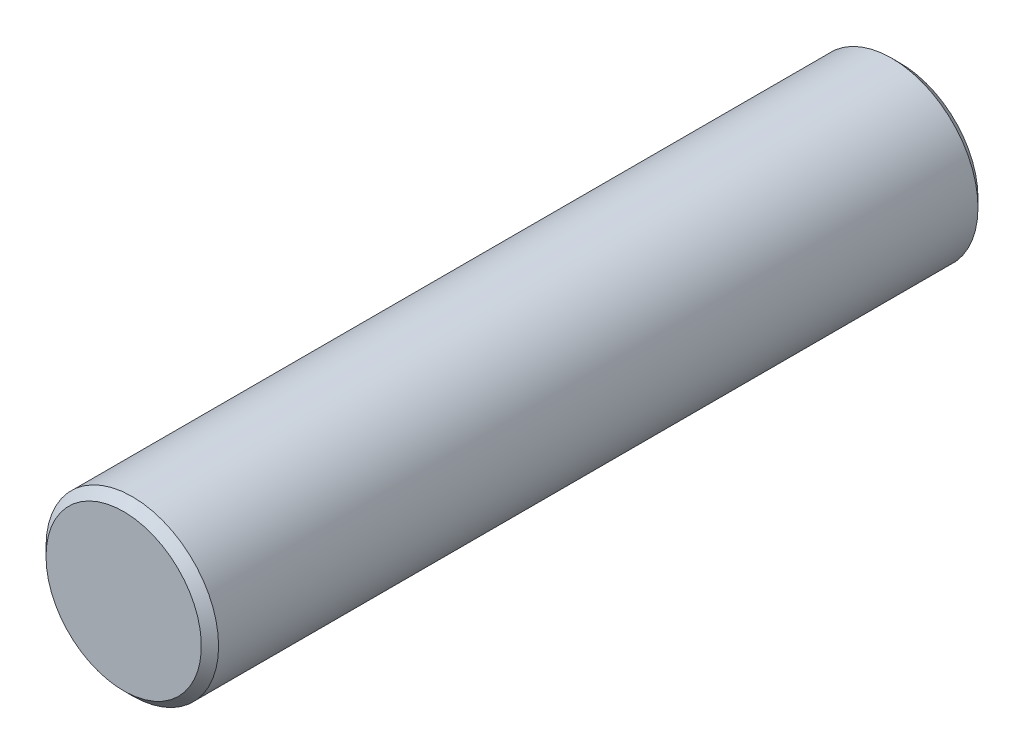
from build123d import *

# Parameters (mm, degrees)
SKETCH1_W     = 45
SKETCH1_H     = 5
CHAMFER1_SIZE = 0.5


with BuildPart() as part:
    # Sketch1 → Revolve1 (revolve)
    with BuildSketch(Plane(origin=(0, 0, 0), x_dir=(0, 0, -1), z_dir=(1, 0, 0))):
        with Locations((0, 2.5)):
            Rectangle(SKETCH1_W, SKETCH1_H)
    revolve(axis=Axis((0, 0, 258.883884114), (0, 0, -1)))

    # Chamfer1
    chamfer1_edges = [part.edges().sort_by_distance(p)[0] for p in [
        (0, -5, -22.5),
        (0, -5, 22.5),
    ]]
    chamfer(chamfer1_edges, length=CHAMFER1_SIZE)


solid = part.part
